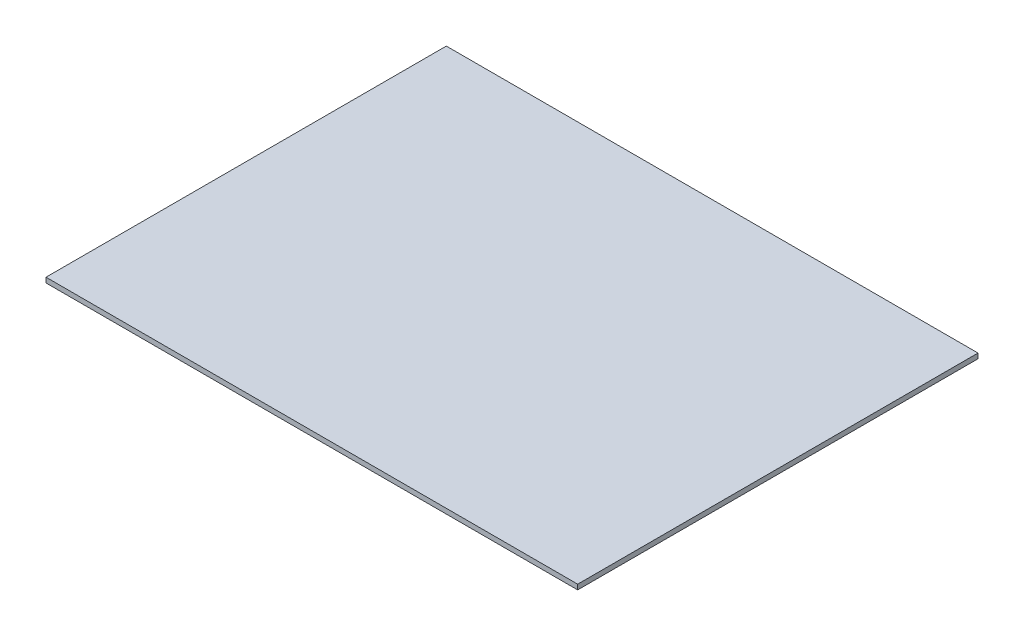
from build123d import *

# Parameters (mm, degrees)
SKETCH_1_W      = 425
SKETCH_1_H      = 320
EXTRUDE_1_DEPTH = 4


with BuildPart() as part:
    # Эскиз1 → Бобышка-Вытянуть1 (new body)
    with BuildSketch(Plane(origin=(0, 0, 0), x_dir=(1, 0, 0), z_dir=(0, 1, 0))):
        Rectangle(SKETCH_1_W, SKETCH_1_H)
    extrude(amount=EXTRUDE_1_DEPTH)


solid = part.part
